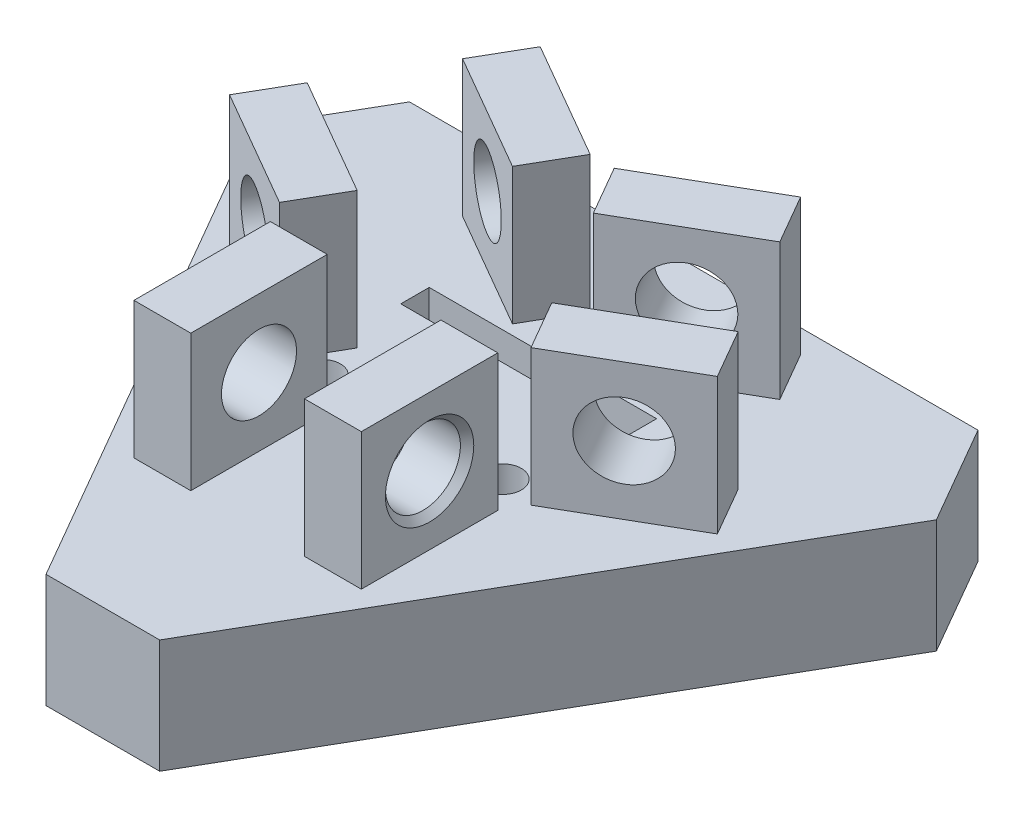
from build123d import *

# Parameters (mm, degrees)
EXTRUDE_1_DEPTH                 = 10
SKETCH_2_W                      = 5
SKETCH_2_H                      = 12
EXTRUDE_4_DEPTH                 = 12
HOLE_WIZARD_G1_16_1_D           = 6.6
HOLE_WIZARD_G1_16_1_DEPTH       = 50
HOLE_WIZARD_G1_16_1_CSINK_D     = 7.773
HOLE_WIZARD_G1_16_1_CSINK_ANGLE = 90
HOLE_WIZARD_G1_16_1_TIP         = 1.982840043
HOLE_WIZARD_G1_16_2_D           = 6.6
HOLE_WIZARD_G1_16_2_DEPTH       = 50
HOLE_WIZARD_G1_16_2_CSINK_D     = 7.773
HOLE_WIZARD_G1_16_2_CSINK_ANGLE = 90
HOLE_WIZARD_G1_16_2_TIP         = 1.982840043
HOLE_WIZARD_G1_16_3_D           = 6.6
HOLE_WIZARD_G1_16_3_DEPTH       = 50
HOLE_WIZARD_G1_16_3_CSINK_D     = 7.773
HOLE_WIZARD_G1_16_3_CSINK_ANGLE = 90
HOLE_WIZARD_G1_16_3_TIP         = 1.982840043
EXTRUDE_5_DEPTH                 = 40
SKETCH_19_W                     = 50
SKETCH_19_H                     = 30
CUT_EXTRUDE_2_DEPTH             = 74
EXTRUDE_6_DEPTH                 = 40
SKETCH_23_R                     = 1.5
CUT_EXTRUDE_3_DEPTH             = 6
SPLIT_BODIES_1_SURFACE_1_BACK   = 101.717
SPLIT_BODIES_1_SURFACE_1_DEPTH  = 203.434
SPLIT_BODIES_1_SURFACE_2_BACK   = 101.717
SPLIT_BODIES_1_SURFACE_2_DEPTH  = 203.434
SKETCH_26_W                     = 78.052093204
SKETCH_26_H                     = 42.58927149
CUT_EXTRUDE_5_DEPTH             = 147
CUT_EXTRUDE_6_DEPTH             = 4
SKETCH_30_W                     = 20
SKETCH_30_H                     = 2.5
CUT_EXTRUDE_7_DEPTH             = 10
HOLE_WIZARD_M4_2_AT_2_COUNT     = 2
HOLE_WIZARD_M4_2_AT_2_PITCH     = 15.909397414


with BuildPart() as part:
    # 草图1 → 凸台-拉伸1 (new body)
    with BuildSketch(Plane(origin=(0, 0, 0), x_dir=(1, 0, 0), z_dir=(0, 1, 0))):
        Polygon((-32.831152269, 24.637065757), (17.168847731, 24.637065757), (22.168847731, 15.976811719), (-2.831152269, -27.32445847), (-12.831152269, -27.32445847), (-37.831152269, 15.976811719), align=None)
    extrude(amount=EXTRUDE_1_DEPTH)

    # 草图2 → 凸台-拉伸4 (add)
    with BuildSketch(Plane(origin=(0, 10, 0), x_dir=(1, 0, 0), z_dir=(0, 1, 0))):
        Polygon((-18.888926711, -0.733069557), (-16.388914662, 3.597050504), (-26.78120281, 9.597079424), (-29.28121486, 5.266959362), align=None)
        Polygon((-11.388890562, 12.257290628), (-8.888878512, 16.58741069), (-19.28116666, 22.58743961), (-21.78117871, 18.257319548), align=None)
        Polygon((-4.273413977, 12.257290628), (6.118874171, 18.257319548), (3.618862121, 22.58743961), (-6.773426027, 16.58741069), align=None)
        Polygon((3.226622172, -0.733069557), (13.618910321, 5.266959362), (11.118898271, 9.597079424), (0.726610123, 3.597050504), align=None)
        with Locations((-0.331152269, -8.591935763)):
            Rectangle(SKETCH_2_W, SKETCH_2_H)
        with Locations((-15.331152269, -8.591935763)):
            Rectangle(SKETCH_2_W, SKETCH_2_H)
    extrude(amount=EXTRUDE_4_DEPTH)

    # G1/16 螺纹孔1
    with Locations(Plane(origin=(4.96034155, 0, -8.591508373), x_dir=(-0.8660240123793532, 0, -0.500002409976558), z_dir=(0.500002409976558, 0, -0.8660240123793532))):
        with Locations((21.991727555, 16)):
            CounterSinkHole(HOLE_WIZARD_G1_16_1_D / 2, HOLE_WIZARD_G1_16_1_CSINK_D / 2, depth=HOLE_WIZARD_G1_16_1_DEPTH, counter_sink_angle=HOLE_WIZARD_G1_16_1_CSINK_ANGLE)
            with Locations((0, 0, -(HOLE_WIZARD_G1_16_1_DEPTH + HOLE_WIZARD_G1_16_1_TIP / 2))):  # 118° drill point
                Cone(0, HOLE_WIZARD_G1_16_1_D / 2, HOLE_WIZARD_G1_16_1_TIP, mode=Mode.SUBTRACT)

    # G1/16 螺纹孔2
    with Locations(Plane(origin=(-8.875955431, 0, -15.373506972), x_dir=(-0.8660240123793504, 0, 0.5000024099765628), z_dir=(-0.5000024099765628, 0, -0.8660240123793506))):
        with Locations((-8.427795735, 16)):
            CounterSinkHole(HOLE_WIZARD_G1_16_2_D / 2, HOLE_WIZARD_G1_16_2_CSINK_D / 2, depth=HOLE_WIZARD_G1_16_2_DEPTH, counter_sink_angle=HOLE_WIZARD_G1_16_2_CSINK_ANGLE)
            with Locations((0, 0, -(HOLE_WIZARD_G1_16_2_DEPTH + HOLE_WIZARD_G1_16_2_TIP / 2))):  # 118° drill point
                Cone(0, HOLE_WIZARD_G1_16_2_D / 2, HOLE_WIZARD_G1_16_2_TIP, mode=Mode.SUBTRACT)

    # G1/16 螺纹孔3
    with Locations(Plane(origin=(2.168847731, 0, 0), x_dir=(0, 0, -1), z_dir=(1, 0, 0))):
        with Locations((-8.591935763, 16)):
            CounterSinkHole(HOLE_WIZARD_G1_16_3_D / 2, HOLE_WIZARD_G1_16_3_CSINK_D / 2, depth=HOLE_WIZARD_G1_16_3_DEPTH, counter_sink_angle=HOLE_WIZARD_G1_16_3_CSINK_ANGLE)
            with Locations((0, 0, -(HOLE_WIZARD_G1_16_3_DEPTH + HOLE_WIZARD_G1_16_3_TIP / 2))):  # 118° drill point
                Cone(0, HOLE_WIZARD_G1_16_3_D / 2, HOLE_WIZARD_G1_16_3_TIP, mode=Mode.SUBTRACT)

    # 草图18 → 凸台-拉伸5 (add)
    with BuildSketch(Plane(origin=(0, 0, 0), x_dir=(-1, 0, 0), z_dir=(0, -1, 0))):
        Polygon((36.516059441, -12.131432542), (30.961139109, 4.077599876), (19.480871434, -15.806807021), align=None)
        Polygon((30.961139109, 4.077599876), (23.915302437, 24.637065757), (-1.237762159, -20.276891949), (19.480871434, -15.806807021), align=None)
        Polygon((23.915302437, 24.637065757), (0, 24.637065757), (-13.377530598, 0.749803781), (-1.237762159, -20.276891949), align=None)
    extrude(amount=EXTRUDE_5_DEPTH)

    # 草图19 → 切除-拉伸2 (cut)
    with BuildSketch(Plane(origin=(-4.125141126, 0, 19.119835281), x_dir=(0.9775078175150543, 0, 0.21089918609837094), z_dir=(-0.21089918609837097, 0, 0.9775078175150544))):
        with Locations((-8.136224319, -15)):
            Rectangle(SKETCH_19_W, SKETCH_19_H)
    extrude(amount=-CUT_EXTRUDE_2_DEPTH, mode=Mode.SUBTRACT)


with BuildPart() as cut_extrude_2_piece_1:
    # of the separate pieces the step leaves, piece 1, a body of its own (cut_extrude_2_pieces)
    add(part.part.solids().sort_by_distance((17.168847731, 0, -24.637065757))[0])



with BuildPart() as cut_extrude_2_piece_2:
    # of the separate pieces the step leaves, piece 2, a body of its own (cut_extrude_2_pieces)
    add(part.part.solids().sort_by_distance((-23.915302437, -30, -24.637065757))[0])


with BuildPart() as cut_extrude_2_piece_1_1:
    add(cut_extrude_2_piece_1.part)

    add(cut_extrude_2_piece_2.part)  # 凸台-拉伸6 merges 切除-拉伸2 piece 2
    # 草图20 → 凸台-拉伸6 (add)
    with BuildSketch(Plane.XZ):
        Polygon((-12.831152269, 27.32445847), (-19.480871434, 15.806807021), (1.237762159, 20.276891949), (-2.831152269, 27.32445847), align=None)
        Polygon((-37.831152269, -15.976811719), (-30.961139109, -4.077599876), (-23.915302437, -24.637065757), (-32.831152269, -24.637065757), align=None)
    extrude(amount=EXTRUDE_6_DEPTH)

    # 草图23 → 切除-拉伸3 (cut)
    with BuildSketch(Plane(origin=(0, -30, 0), x_dir=(1, 0, 0), z_dir=(0, 1, 0))):
        with Locations(Location((0.168847731, -0.188995818, 0), (0, 0, 270))):
            Circle(SKETCH_23_R)
        with Locations(Location((-7.831152269, 13.667410642, 0), (0, 0, 270))):
            Circle(SKETCH_23_R)
    extrude(amount=-CUT_EXTRUDE_3_DEPTH, mode=Mode.SUBTRACT)


with BuildPart() as body_2:
    # Split Bodies 1: the piece behind the surface
    add(cut_extrude_2_piece_1_1.part)
    # Split Bodies 1 surface: a surface, the sketch's curves swept straight by 203.434 mm
    with BuildLine(Plane(origin=(-35.291526612, 0, -20.37557239), x_dir=(-0.4999999999999961, 0, 0.866025403784441), z_dir=(-0.866025403784441, 0, -0.4999999999999961)).offset(-SPLIT_BODIES_1_SURFACE_1_BACK), mode=Mode.PRIVATE) as split_bodies_1_surface_1_path:
        Line((-9.378673602, 0), (48.060747663, 0))
        Line((48.060747663, 0), (48.060747663, -0.001))
        Line((48.060747663, -0.001), (-9.378673602, -0.001))
        Line((-9.378673602, -0.001), (-9.378673602, 0))
    split_bodies_1_surface_1 = Shell.extrude(split_bodies_1_surface_1_path.wire(), (-0.866025404 * SPLIT_BODIES_1_SURFACE_1_DEPTH, 0 * SPLIT_BODIES_1_SURFACE_1_DEPTH, -0.5 * SPLIT_BODIES_1_SURFACE_1_DEPTH))
    split(bisect_by=split_bodies_1_surface_1, keep=Keep.BOTTOM)


with BuildPart() as cut_extrude_2_piece_1_2:
    add(cut_extrude_2_piece_1_1.part)

    # Split Bodies 1: split by a surface, the side it looks to stays
    # Split Bodies 1 surface: a surface, the sketch's curves swept straight by 203.434 mm
    with BuildLine(Plane(origin=(-35.291526612, 0, -20.37557239), x_dir=(-0.4999999999999961, 0, 0.866025403784441), z_dir=(-0.866025403784441, 0, -0.4999999999999961)).offset(-SPLIT_BODIES_1_SURFACE_2_BACK), mode=Mode.PRIVATE) as split_bodies_1_surface_2_path:
        Line((-9.378673602, 0), (48.060747663, 0))
        Line((48.060747663, 0), (48.060747663, -0.001))
        Line((48.060747663, -0.001), (-9.378673602, -0.001))
        Line((-9.378673602, -0.001), (-9.378673602, 0))
    split_bodies_1_surface_2 = Shell.extrude(split_bodies_1_surface_2_path.wire(), (-0.866025404 * SPLIT_BODIES_1_SURFACE_2_DEPTH, 0 * SPLIT_BODIES_1_SURFACE_2_DEPTH, -0.5 * SPLIT_BODIES_1_SURFACE_2_DEPTH))
    split(bisect_by=split_bodies_1_surface_2, keep=Keep.TOP)

    # 草图26 → 切除-拉伸5 (cut)
    with BuildSketch(Plane(origin=(9.708473388, 0, 5.605189724), x_dir=(0.49999999999999983, 0, -0.8660254037844388), z_dir=(0.8660254037844387, 0, 0.4999999999999998))):
        with Locations((-9.034701061, -21.295635745)):
            Rectangle(SKETCH_26_W, SKETCH_26_H)
    extrude(amount=-CUT_EXTRUDE_5_DEPTH, mode=Mode.SUBTRACT)

    # 草图28 → M4 螺纹孔1 (revolve, cut)
    with BuildSketch(Plane(origin=(-7.831152269, 10, -4.429806335), x_dir=(0, 0, 1), z_dir=(1, 0, 0))):
        Polygon((0, 0), (0, 11.091420021), (1.65, 10.1), (1.65, 0), align=None)
    revolve(axis=Axis((-7.831152269, 16.35, -4.429806335), (0, -1, 0)), mode=Mode.SUBTRACT)

    # 草图29 → 切除-拉伸6 (cut)
    with BuildSketch(Plane(origin=(0, 0, 0), x_dir=(-1, 0, 0), z_dir=(0, -1, 0))):
        Polygon((7.831152269, -1.343696357), (12.831152269, 7.316557681), (2.831152269, 7.316557681), align=None)
    extrude(amount=-CUT_EXTRUDE_6_DEPTH, mode=Mode.SUBTRACT)

    # 草图30 → 切除-拉伸7 (cut)
    with BuildSketch(Plane(origin=(0, 0, 0), x_dir=(-1, 0, 0), z_dir=(0, -1, 0))):
        with Locations((7.831152269, 10.124679252)):
            Rectangle(SKETCH_30_W, SKETCH_30_H)
    extrude(amount=-CUT_EXTRUDE_7_DEPTH, mode=Mode.SUBTRACT)

    # 草图32 → M4 螺纹孔2 (revolve, cut)
    with BuildSketch(Plane(origin=(0, 0, 0), x_dir=(0, 0, -1), z_dir=(1, 0, 0))):
        Polygon((0, 0), (0, 11.091420021), (1.65, 10.1), (1.65, 0), align=None)
    hole_wizard_m4_2 = revolve(axis=Axis((0, -6.35, 0), (0, 1, 0)), mode=Mode.SUBTRACT)

    # M4 螺纹孔2 at 2: M4 螺纹孔2 ×2
    with Locations(*[(-i * HOLE_WIZARD_M4_2_AT_2_PITCH, 0, 0) for i in range(1, HOLE_WIZARD_M4_2_AT_2_COUNT)]):
        add(hole_wizard_m4_2, mode=Mode.SUBTRACT)


solid = Compound([body_2.part, cut_extrude_2_piece_1_2.part])
